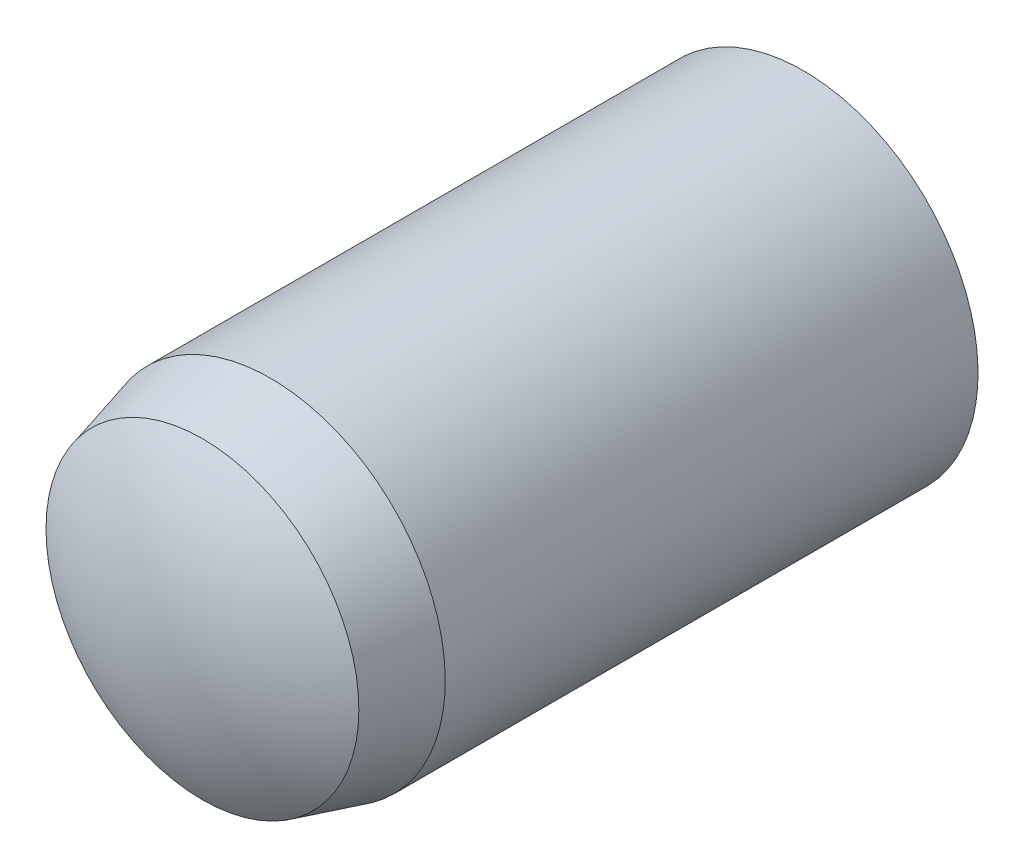
from build123d import *


with BuildPart() as part:
    # Sketch3 → Revolve1 (revolve)
    with BuildSketch(Plane(origin=(0, 0, 0), x_dir=(0, 0, -1), z_dir=(1, 0, 0))):
        with BuildLine():
            Line((-3, 0), (3, 0))
            ThreePointArc((3, 0), (2.885076627, 0.783022988), (2.55, 1.5))
            Line((2.55, 1.5), (-2.025, 1.5))
            Line((-2.025, 1.5), (-2.61, 1.343249722))
            ThreePointArc((-2.61, 1.343249722), (-2.90052754, 0.699360389), (-3, 0))
        make_face()
    revolve(axis=Axis((0, 0, 3), (0, 0, -1)))


solid = part.part
